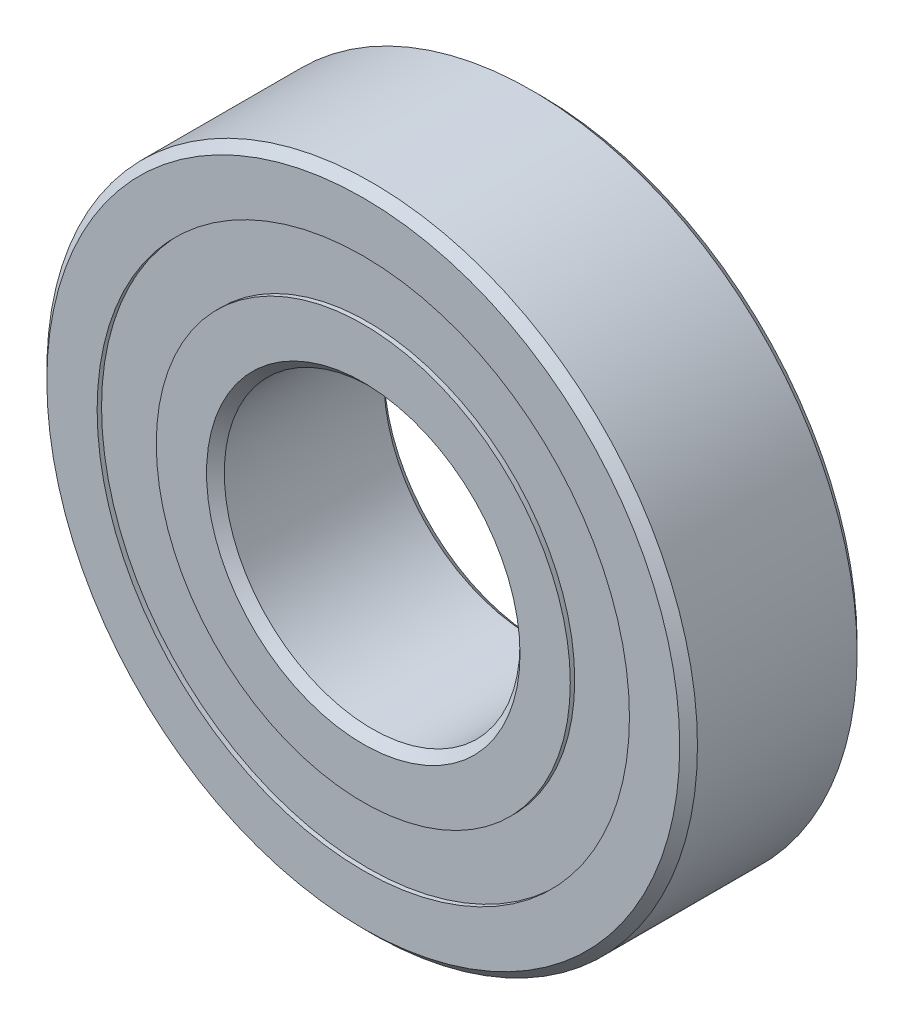
from build123d import *

# Parameters (mm, degrees)
CIRPATTERN1_COUNT = 10
SKETCH5_W         = 1.183333333
SKETCH5_H         = 2


with BuildPart() as part:
    # Sketch3 → Revolve1 (revolve)
    with BuildSketch(Plane(origin=(0, 0, 0), x_dir=(0, 0, -1), z_dir=(1, 0, 0))):
        with BuildLine():
            Line((-3, 10.7), (-3, 9))
            Line((-3, 9), (-1.333333333, 9))
            ThreePointArc((-1.333333333, 9), (0, 9.666666667), (1.333333333, 9))
            Line((1.333333333, 9), (3, 9))
            Line((3, 9), (3, 10.7))
            Line((3, 10.7), (2.7, 11))
            Line((2.7, 11), (-2.7, 11))
            Line((-2.7, 11), (-3, 10.7))
        make_face()
        with BuildLine():
            Line((-3, 5.3), (-3, 7))
            Line((-3, 7), (-1.333333333, 7))
            ThreePointArc((-1.333333333, 7), (0, 6.333333333), (1.333333333, 7))
            Line((1.333333333, 7), (3, 7))
            Line((3, 7), (3, 5.3))
            Line((3, 5.3), (2.7, 5))
            Line((2.7, 5), (-2.7, 5))
            Line((-2.7, 5), (-3, 5.3))
        make_face()
    revolve(axis=Axis((0, 0, 3), (0, 0, -1)))


with BuildPart() as body_2:
    # Sketch4 → Revolve2 (revolve)
    with BuildSketch(Plane(origin=(0, 0, 0), x_dir=(0, 0, -1), z_dir=(1, 0, 0))):
        with BuildLine():
            Line((-1.666666667, 8), (1.666666667, 8))
            ThreePointArc((1.666666667, 8), (0, 9.666666667), (-1.666666667, 8))
        make_face()
    revolve(axis=Axis((0, 8, 1.666666667), (0, 0, -1)))


with BuildPart() as cirpattern1_1:
    # CirPattern1: pattern copy
    add(body_2.part.rotate(Axis((0, 0, 0), (0, 0, 1)), 1 * 360 / CIRPATTERN1_COUNT))


with BuildPart() as cirpattern1_2:
    # CirPattern1: pattern copy
    add(body_2.part.rotate(Axis((0, 0, 0), (0, 0, 1)), 2 * 360 / CIRPATTERN1_COUNT))


with BuildPart() as cirpattern1_3:
    # CirPattern1: pattern copy
    add(body_2.part.rotate(Axis((0, 0, 0), (0, 0, 1)), 3 * 360 / CIRPATTERN1_COUNT))


with BuildPart() as cirpattern1_4:
    # CirPattern1: pattern copy
    add(body_2.part.rotate(Axis((0, 0, 0), (0, 0, 1)), 4 * 360 / CIRPATTERN1_COUNT))


with BuildPart() as cirpattern1_5:
    # CirPattern1: pattern copy
    add(body_2.part.rotate(Axis((0, 0, 0), (0, 0, 1)), 5 * 360 / CIRPATTERN1_COUNT))


with BuildPart() as cirpattern1_6:
    # CirPattern1: pattern copy
    add(body_2.part.rotate(Axis((0, 0, 0), (0, 0, 1)), 6 * 360 / CIRPATTERN1_COUNT))


with BuildPart() as cirpattern1_7:
    # CirPattern1: pattern copy
    add(body_2.part.rotate(Axis((0, 0, 0), (0, 0, 1)), 7 * 360 / CIRPATTERN1_COUNT))


with BuildPart() as cirpattern1_8:
    # CirPattern1: pattern copy
    add(body_2.part.rotate(Axis((0, 0, 0), (0, 0, 1)), 8 * 360 / CIRPATTERN1_COUNT))


with BuildPart() as cirpattern1_9:
    # CirPattern1: pattern copy
    add(body_2.part.rotate(Axis((0, 0, 0), (0, 0, 1)), 9 * 360 / CIRPATTERN1_COUNT))


with BuildPart() as body_12:
    # Sketch5 → Revolve3 (revolve)
    with BuildSketch(Plane(origin=(0, 0, 0), x_dir=(0, 0, -1), z_dir=(1, 0, 0))):
        with Locations((-2.258333333, 8)):
            Rectangle(SKETCH5_W, SKETCH5_H)
        with Locations((2.258333333, 8)):
            Rectangle(SKETCH5_W, SKETCH5_H)
    revolve(axis=Axis((0, 0, 3), (0, 0, -1)))


solid = Compound([part.part, body_2.part, cirpattern1_1.part, cirpattern1_2.part, cirpattern1_3.part, cirpattern1_4.part, cirpattern1_5.part, cirpattern1_6.part, cirpattern1_7.part, cirpattern1_8.part, cirpattern1_9.part, body_12.part])
